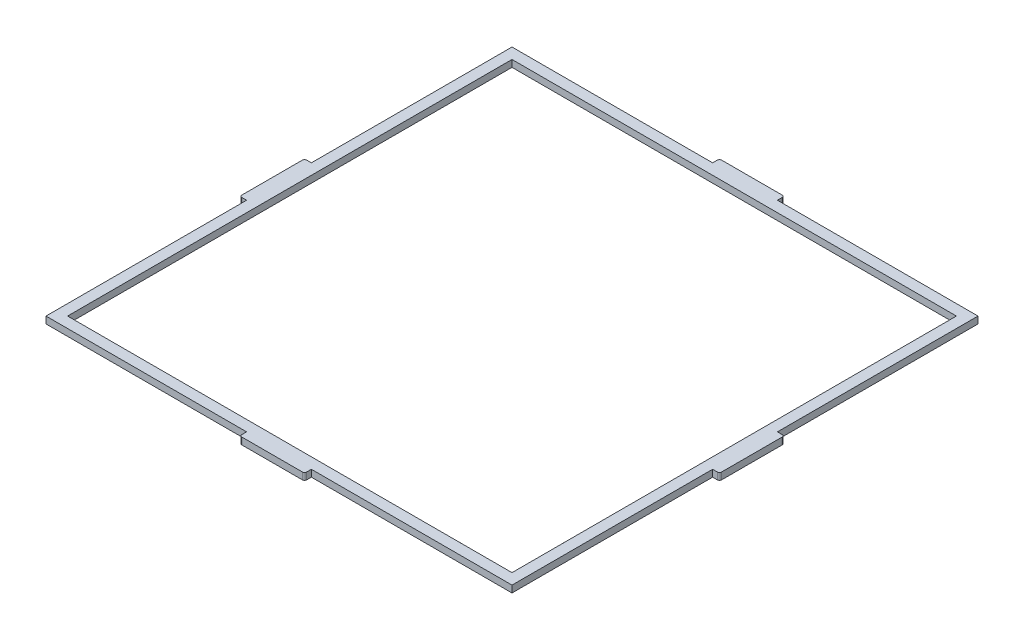
from build123d import *

# Parameters (mm, degrees)
SKETCH1_W           = 215.91
SKETCH1_H           = 215.91
BOSS_EXTRUDE1_DEPTH = 3.175
SKETCH2_W           = 205.91
SKETCH2_H           = 205.91
CUT_EXTRUDE1_DEPTH  = 4.175
SKETCH4_W           = 3.175
SKETCH4_H           = 30
SKETCH4_W_2         = 30
SKETCH4_H_2         = 3.175
BOSS_EXTRUDE2_DEPTH = 3.175
FILLET1_R           = 1


with BuildPart() as part:
    # Sketch1 → Boss-Extrude1 (new body)
    with BuildSketch(Plane(origin=(0, 0, 0), x_dir=(1, 0, 0), z_dir=(0, 1, 0))):
        Rectangle(SKETCH1_W, SKETCH1_H)
    extrude(amount=BOSS_EXTRUDE1_DEPTH)

    # Sketch2 → Cut-Extrude1 (cut, through all)
    with BuildSketch(Plane(origin=(0, 3.175, 0), x_dir=(1, 0, 0), z_dir=(0, 1, 0))):
        Rectangle(SKETCH2_W, SKETCH2_H)
    extrude(amount=-CUT_EXTRUDE1_DEPTH, mode=Mode.SUBTRACT)

    # Sketch4 → Boss-Extrude2 (add)
    with BuildSketch(Plane(origin=(0, 3.175, 0), x_dir=(1, 0, 0), z_dir=(0, 1, 0))):
        with Locations((-109.5425, 0)):
            Rectangle(SKETCH4_W, SKETCH4_H)
        with Locations((0, 109.5425)):
            Rectangle(SKETCH4_W_2, SKETCH4_H_2)
        with Locations((0, -109.5425)):
            Rectangle(SKETCH4_W_2, SKETCH4_H_2)
        with Locations((109.5425, 0)):
            Rectangle(SKETCH4_W, SKETCH4_H)
    extrude(amount=-BOSS_EXTRUDE2_DEPTH)

    # Fillet1
    fillet1_edges = [part.edges().sort_by_distance(p)[0] for p in [
        (-111.13, 1.5875, 15),
        (-111.13, 1.5875, -15),
        (-15, 1.5875, 111.13),
        (15, 1.5875, 111.13),
        (-15, 1.5875, -111.13),
        (15, 1.5875, -111.13),
        (111.13, 1.5875, 15),
        (111.13, 1.5875, -15),
    ]]
    fillet(fillet1_edges, radius=FILLET1_R)


solid = part.part
